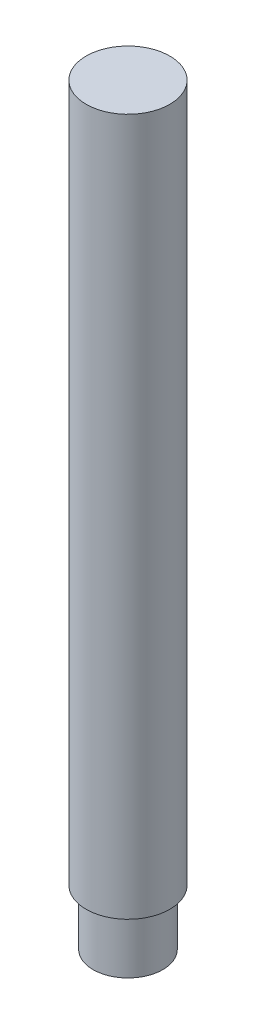
from build123d import *


with BuildPart() as part:
    # Sketch1 → Revolve1 (revolve)
    with BuildSketch(Plane.XY):
        Polygon((0, 54), (3, 54), (3, 4), (2.5, 4), (2.5, 0), (0, 0), align=None)
    revolve(axis=Axis((0, 48.895398485, 0), (0, -1, 0)))


solid = part.part
